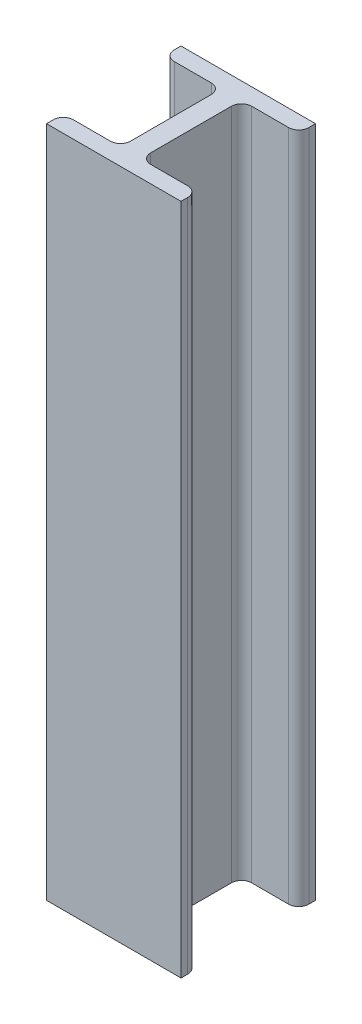
from build123d import *

# Parameters (mm, degrees)
BOSS_EXTRUDE1_DEPTH = 200
FILLET1_R           = 3
FILLET2_R           = 3


with BuildPart() as part:
    # Sketch1 → Boss-Extrude1 (new body)
    with BuildSketch(Plane(origin=(0, 0, 0), x_dir=(1, 0, 0), z_dir=(0, 1, 0))):
        Polygon((-20, 5), (-20, 0), (0, 0), (0, 40), (-20, 40), (-20, 35), (-3, 35), (-3, 5), align=None)
        Polygon((0, 40), (0, 0), (20, 0), (20, 5), (3, 5), (3, 35), (20, 35), (20, 40), align=None)
    extrude(amount=BOSS_EXTRUDE1_DEPTH)

    # Fillet1
    fillet1_edges = [part.edges().sort_by_distance(p)[0] for p in [
        (-3, 100, -5),
        (-3, 100, -35),
        (3, 100, -35),
        (3, 100, -5),
    ]]
    fillet(fillet1_edges, radius=FILLET1_R)

    # Fillet2
    fillet2_edges = [part.edges().sort_by_distance(p)[0] for p in [
        (-20, 100, -5),
        (-20, 100, -35),
        (20, 100, -35),
        (20, 100, -5),
    ]]
    fillet(fillet2_edges, radius=FILLET2_R)


solid = part.part
